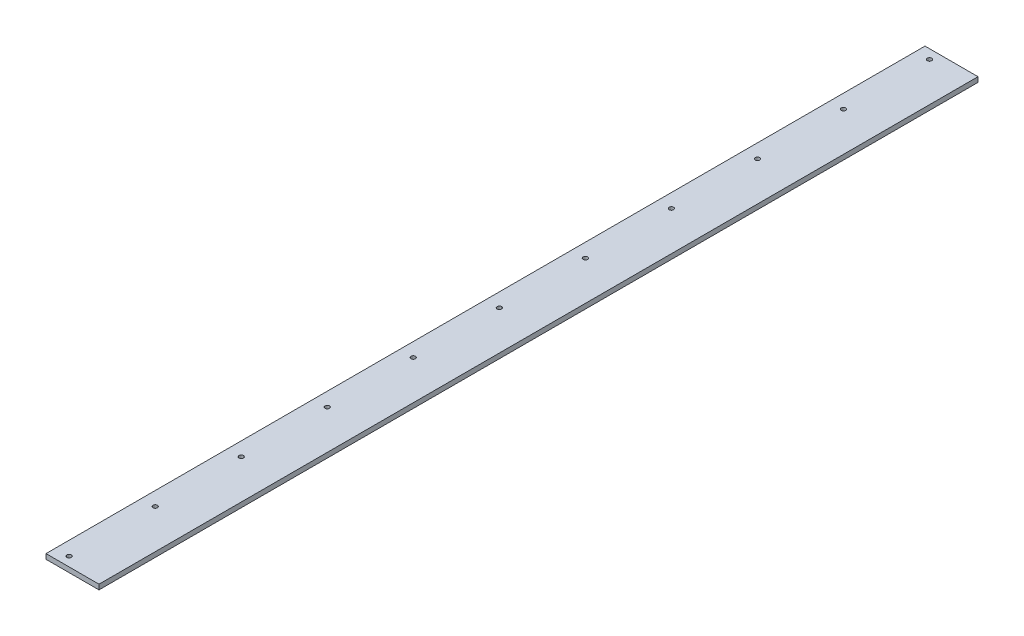
from build123d import *

# Parameters (mm, degrees)
SKETCH_1_W          = 85
SKETCH_1_H          = 8
EXTRUDE_1_DEPTH     = 705
HOLE_WIZARD_M6_51_D = 7.1


with BuildPart() as part:
    # Эскиз1 → Бобышка-Вытянуть1 (new body)
    with BuildSketch(Plane.XY):
        with Locations((10.313375116, 4)):
            Rectangle(SKETCH_1_W, SKETCH_1_H)
    extrude(amount=EXTRUDE_1_DEPTH)

    # Отверстие с зазором M6.51 (through all)
    with Locations(Plane(origin=(0, 0, 0), x_dir=(-1, 0, 0), z_dir=(0, -1, 0))):
        with Locations((10.006096654, -690), (10.006096654, -552), (10.006096654, -414), (10.006096654, -138), (10.006096654, 0), (10.006096654, -276)):
            Hole(HOLE_WIZARD_M6_51_D / 2)

    # Зеркальное отражение1: part across plane


with BuildPart() as part_1:
    add(part.part)
    add(part.part.mirror(Plane(origin=(0, 0, 0), x_dir=(1, 0, 0), z_dir=(0, 0, -1))))


solid = part_1.part
